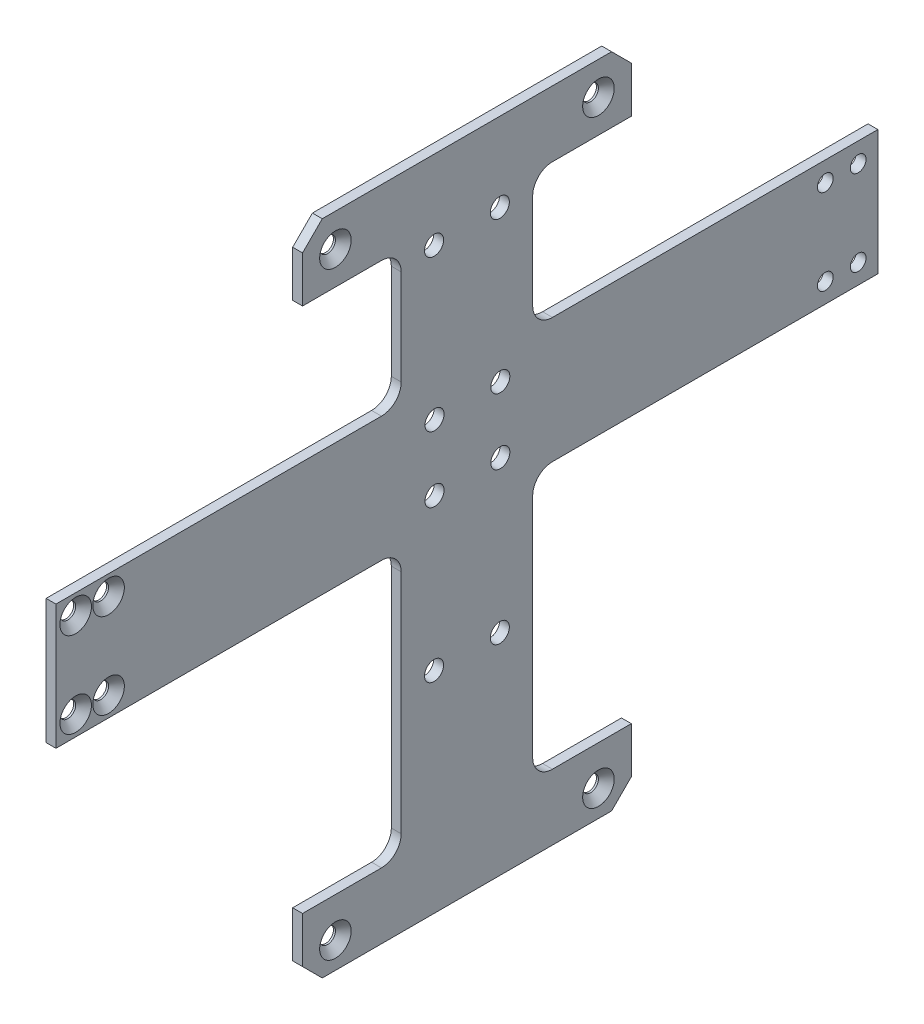
from build123d import *

# Parameters (mm, degrees)
SKETCH1_W                       = 1.5
SKETCH1_H                       = 25
BOSS_EXTRUDE1_DEPTH             = 73
BOSS_EXTRUDE1_DEPTH_BACK        = 73
FILLET1_R                       = 1
BOSS_EXTRUDE2_REACH             = 2.75
SKETCH10_W                      = 20
SKETCH10_H                      = 25
BOSS_EXTRUDE2_DIRECTION_2_REACH = 2.75
SKETCH16_W                      = 40.5
SKETCH16_H                      = 3
CUT_EXTRUDE2_DEPTH              = 10
SKETCH21_W                      = 65
SKETCH21_H                      = 47
BOSS_EXTRUDE4_DEPTH             = 1.5
FILLET4_R                       = 1.5
SKETCH17_W                      = 22.5
SKETCH17_H                      = 25
BOSS_EXTRUDE3_DEPTH             = 1.5
M2_CLEARANCE_HOLE4_D            = 2.4
M2_CLEARANCE_HOLE4_DEPTH        = 1.5
SKETCH22_OUTSIDE_W              = 183.058
SKETCH22_OUTSIDE_H              = 134.058
SKETCH22_OUTSIDE_W_2            = 125
SKETCH22_OUTSIDE_H_2            = 119
CUT_EXTRUDE4_DEPTH              = 10
M2_CLEARANCE_HOLE5_D            = 2.4
M2_CLEARANCE_HOLE5_DEPTH        = 11.5
SKETCH25_W                      = 65
SKETCH25_H                      = 2.5
SKETCH25_H_2                    = 0.5
BOSS_EXTRUDE5_DEPTH             = 1.5
M2_5_CLEARANCE_HOLE1_D          = 2.9
M2_5_CLEARANCE_HOLE1_DEPTH      = 11.5
SKETCH29_W                      = 7.5
SKETCH29_H                      = 30.5
SKETCH29_H_2                    = 50.5
CUT_EXTRUDE5_DEPTH              = 10
SKETCH31_W                      = 15
SKETCH31_H                      = 20.5
SKETCH31_H_2                    = 40.5
CUT_EXTRUDE7_DEPTH              = 10
FILLET5_R                       = 3
CHAMFER1_SIZE                   = 1.2
CHAMFER2_SIZE                   = 3
M2_5_CLEARANCE_HOLE2_D          = 2.9
M2_5_CLEARANCE_HOLE2_DEPTH      = 10


with BuildPart() as part:
    # Sketch1 → Boss-Extrude1 (new body, two sides)
    with BuildSketch(Plane.XY) as boss_extrude1_sk:
        Rectangle(SKETCH1_W, SKETCH1_H)
    extrude(amount=BOSS_EXTRUDE1_DEPTH)
    extrude(boss_extrude1_sk.sketch, amount=-BOSS_EXTRUDE1_DEPTH_BACK)

    # Fillet1
    fillet1_edges = [part.edges().sort_by_distance(p)[0] for p in [
        (0, -12.5, 73),
        (0, 12.5, -73),
        (0, 12.5, 73),
        (0, -12.5, -73),
    ]]
    fillet(fillet1_edges, radius=FILLET1_R)

    # Boss-Extrude2: up to this face of the body (flat: up to its plane)
    boss_extrude2_end = Plane(part.part.faces().sort_by_distance((0.75, 0, 0))[0])
    # Sketch10 → Boss-Extrude2 (add, up to the picked face)
    with BuildSketch(Plane(origin=(0, 0, 0), x_dir=(0, 0, -1), z_dir=(1, 0, 0)), mode=Mode.PRIVATE) as boss_extrude2_sk1:
        with Locations((0, 25)):
            Rectangle(SKETCH10_W, SKETCH10_H)
    boss_extrude2_tool1 = split(extrude(boss_extrude2_sk1.sketch, amount=BOSS_EXTRUDE2_REACH, mode=Mode.PRIVATE), bisect_by=boss_extrude2_end, keep=Keep.BOTH, mode=Mode.PRIVATE)
    add(boss_extrude2_tool1.solids().sort_by_distance((0, 25, 0))[0])

    # Boss-Extrude2 direction 2: up to this face of the body (flat: up to its plane)
    boss_extrude2_direction_2_end = Plane(part.part.faces().sort_by_distance((-0.75, 0, 0))[0])
    # Sketch10 → Boss-Extrude2 direction 2 (add, up to the picked face)
    with BuildSketch(Plane(origin=(0, 0, 0), x_dir=(0, 0, -1), z_dir=(1, 0, 0)), mode=Mode.PRIVATE) as boss_extrude2_direction_2_sk1:
        with Locations((0, 25)):
            Rectangle(SKETCH10_W, SKETCH10_H)
    boss_extrude2_direction_2_tool1 = split(extrude(boss_extrude2_direction_2_sk1.sketch, amount=-BOSS_EXTRUDE2_DIRECTION_2_REACH, mode=Mode.PRIVATE), bisect_by=boss_extrude2_direction_2_end, keep=Keep.BOTH, mode=Mode.PRIVATE)
    add(boss_extrude2_direction_2_tool1.solids().sort_by_distance((0, 25, 0))[0])

    # Sketch16 → Cut-Extrude2 (cut)
    with BuildSketch(Plane.ZY.offset(0.75)):
        with Locations((-52.75, 11)):
            Rectangle(SKETCH16_W, SKETCH16_H)
        with Locations((-52.75, -11)):
            Rectangle(SKETCH16_W, SKETCH16_H)
    cut_extrude2 = extrude(amount=-CUT_EXTRUDE2_DEPTH, mode=Mode.SUBTRACT)

    # Mirror3: Cut-Extrude2 across plane
    add(cut_extrude2.mirror(Plane.XY), mode=Mode.SUBTRACT)

    # Sketch21 → Boss-Extrude4 (add)
    with BuildSketch(Plane(origin=(0.75, 0, 0), x_dir=(0, 0, -1), z_dir=(1, 0, 0))):
        with Locations((0, -36)):
            Rectangle(SKETCH21_W, SKETCH21_H)
    extrude(amount=-BOSS_EXTRUDE4_DEPTH)

    # Fillet4
    fillet4_edges = [part.edges().sort_by_distance(p)[0] for p in [
        (0, 9.5, 73),
        (0, -9.5, 73),
        (0, 9.5, -73),
        (0, -9.5, -73),
    ]]
    fillet(fillet4_edges, radius=FILLET4_R)

    # Sketch17 → Boss-Extrude3 (add)
    with BuildSketch(Plane.ZY.offset(0.75)):
        with Locations((-21.25, 25)):
            Rectangle(SKETCH17_W, SKETCH17_H)
        with Locations((21.25, 25)):
            Rectangle(SKETCH17_W, SKETCH17_H)
    extrude(amount=-BOSS_EXTRUDE3_DEPTH)

    # M2 Clearance Hole4
    with Locations(Plane(origin=(0.75, 0, 0), x_dir=(0, 0, -1), z_dir=(1, 0, 0))):
        with Locations((20, 35), (-20, 35), (-20, -56), (20, -56)):
            Hole(M2_CLEARANCE_HOLE4_D / 2, depth=M2_CLEARANCE_HOLE4_DEPTH)

    # Sketch22 outside → Cut-Extrude4 (cut)
    with BuildSketch(Plane.ZY.offset(0.75)):
        with Locations((0, -11)):
            Rectangle(SKETCH22_OUTSIDE_W, SKETCH22_OUTSIDE_H)
        Rectangle(SKETCH22_OUTSIDE_W_2, SKETCH22_OUTSIDE_H_2, mode=Mode.SUBTRACT)
    extrude(amount=-CUT_EXTRUDE4_DEPTH, mode=Mode.SUBTRACT)

    # M2 Clearance Hole5
    with Locations(Plane(origin=(0.75, 0, 0), x_dir=(0, 0, -1), z_dir=(1, 0, 0))):
        with Locations((-54.5, -6.5), (-54.5, 6.5), (-59.5, 6.5), (-59.5, -6.5)):
            m2_clearance_hole5 = Hole(M2_CLEARANCE_HOLE5_D / 2, depth=M2_CLEARANCE_HOLE5_DEPTH)

    # Mirror4: M2 Clearance Hole5 across plane
    add(m2_clearance_hole5.mirror(Plane.XY), mode=Mode.SUBTRACT)

    # Sketch25 → Boss-Extrude5 (add)
    with BuildSketch(Plane(origin=(0.75, 0, 0), x_dir=(0, 0, -1), z_dir=(1, 0, 0))):
        with Locations((0, 38.75)):
            Rectangle(SKETCH25_W, SKETCH25_H)
        with Locations((0, -59.75)):
            Rectangle(SKETCH25_W, SKETCH25_H_2)
    extrude(amount=-BOSS_EXTRUDE5_DEPTH)

    # M2.5 Clearance Hole1
    with Locations(Plane(origin=(0.75, 0, 0), x_dir=(0, 0, -1), z_dir=(1, 0, 0))):
        with Locations((-5, -28), (5, -28), (5, 28), (-5, 28)):
            Hole(M2_5_CLEARANCE_HOLE1_D / 2, depth=M2_5_CLEARANCE_HOLE1_DEPTH)

    # Sketch29 → Cut-Extrude5 (cut)
    with BuildSketch(Plane(origin=(0.75, 0, 0), x_dir=(0, 0, -1), z_dir=(1, 0, 0))):
        with Locations((-28.75, 24.75)):
            Rectangle(SKETCH29_W, SKETCH29_H)
        with Locations((-28.75, -34.75)):
            Rectangle(SKETCH29_W, SKETCH29_H_2)
        with Locations((28.75, -34.75)):
            Rectangle(SKETCH29_W, SKETCH29_H_2)
        with Locations((28.75, 24.75)):
            Rectangle(SKETCH29_W, SKETCH29_H)
    extrude(amount=-CUT_EXTRUDE5_DEPTH, mode=Mode.SUBTRACT)

    # Sketch31 → Cut-Extrude7 (cut)
    with BuildSketch(Plane(origin=(0.75, 0, 0), x_dir=(0, 0, -1), z_dir=(1, 0, 0))):
        with Locations((-17.5, 19.75)):
            Rectangle(SKETCH31_W, SKETCH31_H)
        with Locations((-17.5, -29.75)):
            Rectangle(SKETCH31_W, SKETCH31_H_2)
        with Locations((17.5, -29.75)):
            Rectangle(SKETCH31_W, SKETCH31_H_2)
        with Locations((17.5, 19.75)):
            Rectangle(SKETCH31_W, SKETCH31_H)
    extrude(amount=-CUT_EXTRUDE7_DEPTH, mode=Mode.SUBTRACT)

    # Fillet5
    fillet5_edges = [part.edges().sort_by_distance(p)[0] for p in [
        (0, 30, 10),
        (0, 9.5, 10),
        (0, -9.5, 10),
        (0, -50, 10),
        (0, -9.5, -10),
        (0, -50, -10),
        (0, 9.5, -10),
        (0, 30, -10),
    ]]
    fillet(fillet5_edges, radius=FILLET5_R)

    # Chamfer1
    chamfer1_edges = [part.edges().sort_by_distance(p)[0] for p in [
        (0.75, -56, -21.2),
        (0.75, -56, 18.8),
        (0.75, 35, 18.8),
        (0.75, 35, -21.2),
        (0.75, -6.5, 58.3),
        (0.75, 6.5, 58.3),
        (0.75, 6.5, 53.3),
        (0.75, -6.5, 53.3),
    ]]
    chamfer(chamfer1_edges, length=CHAMFER1_SIZE)

    # Chamfer2
    chamfer2_edges = [part.edges().sort_by_distance(p)[0] for p in [
        (0, 40, 25),
        (0, -60, 25),
        (0, -60, -25),
        (0, 40, -25),
    ]]
    chamfer(chamfer2_edges, length=CHAMFER2_SIZE)

    # M2.5 Clearance Hole2
    with Locations(Plane.ZY.offset(0.75)):
        with Locations((-5.075, -5), (4.925, -5), (-5.075, 5), (4.925, 5)):
            Hole(M2_5_CLEARANCE_HOLE2_D / 2, depth=M2_5_CLEARANCE_HOLE2_DEPTH)


solid = part.part
